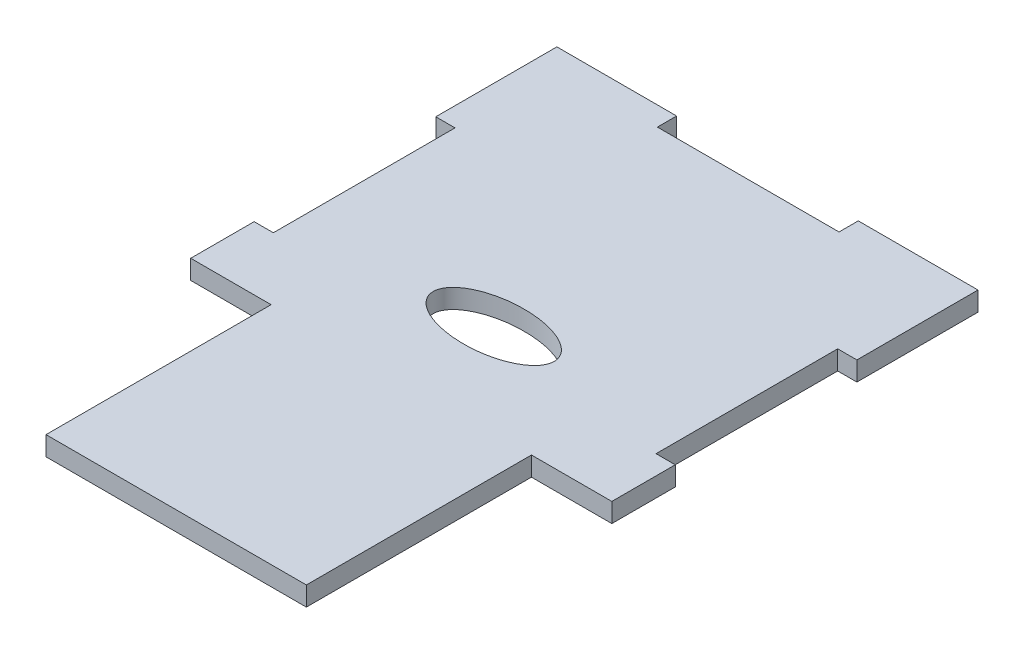
from build123d import *

# Parameters (mm, degrees)
BOSS_EXTRUDE1_DEPTH = 3.175


with BuildPart() as part:
    # Sketch1 → Boss-Extrude1 (new body)
    with BuildSketch(Plane(origin=(0, 0, 0), x_dir=(1, 0, 0), z_dir=(0, 1, 0))):
        Polygon((49.775, 91.3), (19.775, 91.3), (19.775, 94.475), (0, 94.475), (0, 74.475), (3.175, 74.475), (3.175, 44.475), (0, 44.475), (0, 34), (13.275, 34), (13.275, -3.175), (56.275, -3.175), (56.275, 34), (69.55, 34), (69.55, 44.475), (66.375, 44.475), (66.375, 74.475), (69.55, 74.475), (69.55, 94.475), (49.775, 94.475), align=None)
        with BuildLine():
            add(Edge.make_bspline(
                [(24.775, 49.271255677), (24.775, 40.611001639), (39.775, 44.941128658), (54.775, 49.271255677), (39.775, 53.601382696), (24.775, 57.931509715), (24.775, 49.271255677)],
                knots=[0, 0, 0, 2.094395102, 2.094395102, 4.188790205, 4.188790205, 6.283185307, 6.283185307, 6.283185307], degree=2, weights=[1, 0.5, 1, 0.5, 1, 0.5, 1]))
        make_face(mode=Mode.SUBTRACT)
    extrude(amount=BOSS_EXTRUDE1_DEPTH)


solid = part.part
